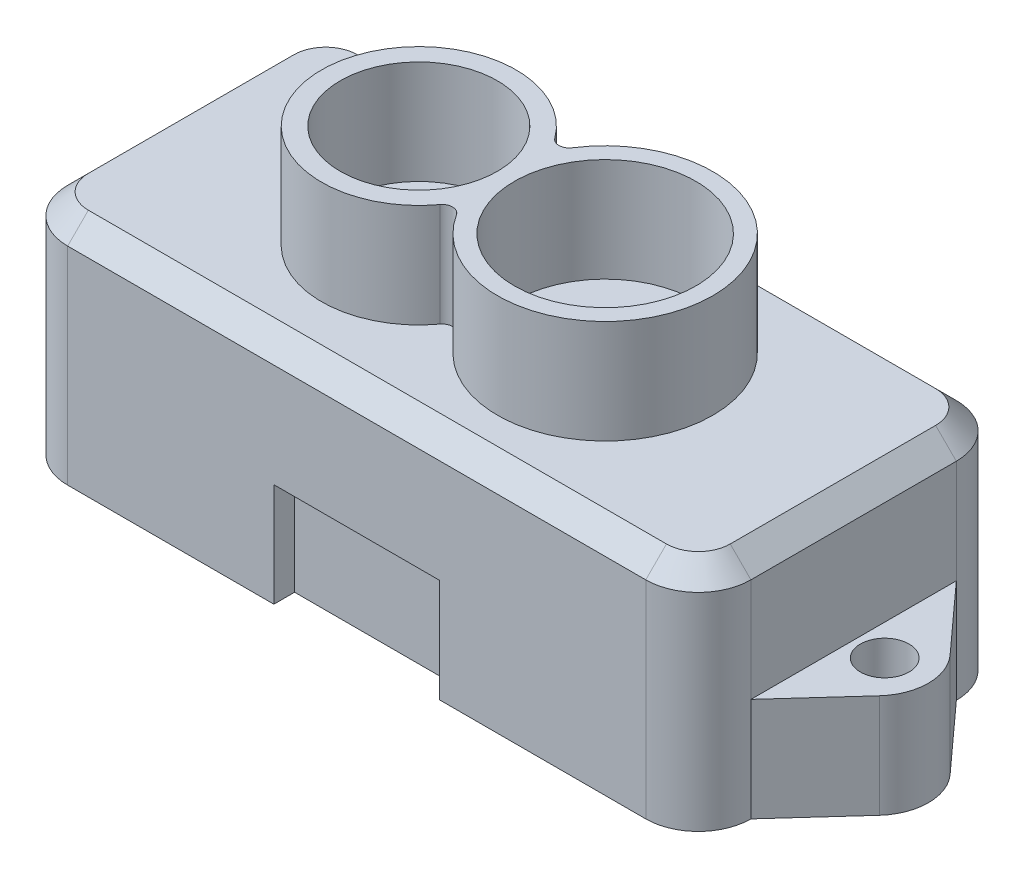
from build123d import *

# Parameters (mm, degrees)
BOSS_EXTRUDE1_DEPTH = 5.5
SKETCH2_R           = 1.175
BOSS_EXTRUDE2_DEPTH = 5
CHAMFER1_SIZE       = 1
SKETCH3_R           = 3.793643162
SKETCH3_R_2         = 4.381481481
BOSS_EXTRUDE3_DEPTH = 5
SKETCH4_W           = 8
SKETCH4_H           = 5
CUT_EXTRUDE1_DEPTH  = 1


with BuildPart() as part:
    # Sketch1 → Boss-Extrude1 (new body, symmetric)
    with BuildSketch(Plane(origin=(0, 0, 0), x_dir=(1, 0, 0), z_dir=(0, 1, 0))):
        with BuildLine():
            Line((-13.96, 7.5), (13.96, 7.5))
            ThreePointArc((13.96, 7.5), (15.756051224, 6.756051224), (16.5, 4.96))
            Line((16.5, 4.96), (16.5, -4.96))
            ThreePointArc((16.5, -4.96), (15.756051224, -6.756051224), (13.96, -7.5))
            Line((13.96, -7.5), (-13.96, -7.5))
            ThreePointArc((-13.96, -7.5), (-15.756051224, -6.756051224), (-16.5, -4.96))
            Line((-16.5, -4.96), (-16.5, 4.96))
            ThreePointArc((-16.5, 4.96), (-15.756051224, 6.756051224), (-13.96, 7.5))
        make_face()
    extrude(amount=BOSS_EXTRUDE1_DEPTH, both=True)

    # Sketch2 → Boss-Extrude2 (add)
    with BuildSketch(Plane.XZ.offset(5.5)):
        with BuildLine():
            Line((-16.5, 4.96), (-19.451582405, 1.706700282))
            ThreePointArc((-19.451582405, 1.706700282), (-20.110419428, 0), (-19.451582405, -1.706700282))
            Line((-19.451582405, -1.706700282), (-16.5, -4.96))
            Line((-16.5, -4.96), (16.5, -4.96))
            Line((16.5, -4.96), (19.451582406, -1.706700282))
            ThreePointArc((19.451582406, -1.706700282), (20.110419428, 0), (19.451582405, 1.706700282))
            Line((19.451582405, 1.706700282), (16.5, 4.96))
            Line((16.5, 4.96), (-15.93880857, 4.96))
            Line((-15.93880857, 4.96), (-16.5, 4.96))
        make_face()
        with Locations((-18, 0)):
            Circle(SKETCH2_R, mode=Mode.SUBTRACT)
        with Locations((18, 0)):
            Circle(SKETCH2_R, mode=Mode.SUBTRACT)
    extrude(amount=-BOSS_EXTRUDE2_DEPTH)

    # Chamfer1
    chamfer1_edges = [part.edges().sort_by_distance(p)[0] for p in [
        (-15.756051224, 5.5, -6.756051224),
        (-16.5, 5.5, 0),
        (-15.756051224, 5.5, 6.756051224),
        (0, 5.5, 7.5),
        (15.756051224, 5.5, 6.756051224),
        (16.5, 5.5, 0),
        (15.756051224, 5.5, -6.756051224),
        (0, 5.5, -7.5),
    ]]
    chamfer(chamfer1_edges, length=CHAMFER1_SIZE)

    # Sketch3 → Boss-Extrude3 (add)
    with BuildSketch(Plane(origin=(0, 5.5, 0), x_dir=(1, 0, 0), z_dir=(0, 1, 0))):
        with BuildLine():
            ThreePointArc((-0.706356838, 2.774575924), (-9.2, 0), (-0.706356838, -2.774575924))
            ThreePointArc((-0.706356838, -2.774575924), (-0.287091072, -2.569989708), (0.118518519, -2.800467823))
            ThreePointArc((0.118518519, -2.800467823), (9.7, 0), (0.118518519, 2.800467823))
            ThreePointArc((0.118518519, 2.800467823), (-0.287091072, 2.569989708), (-0.706356838, 2.774575924))
        make_face()
        with Locations((-4.5, 0)):
            Circle(SKETCH3_R, mode=Mode.SUBTRACT)
        with Locations((4.5, 0)):
            Circle(SKETCH3_R_2, mode=Mode.SUBTRACT)
    extrude(amount=BOSS_EXTRUDE3_DEPTH)

    # Sketch4 → Cut-Extrude1 (cut)
    with BuildSketch(Plane.XY.offset(7.5)):
        with Locations((0, -3)):
            Rectangle(SKETCH4_W, SKETCH4_H)
    extrude(amount=-CUT_EXTRUDE1_DEPTH, mode=Mode.SUBTRACT)


solid = part.part
